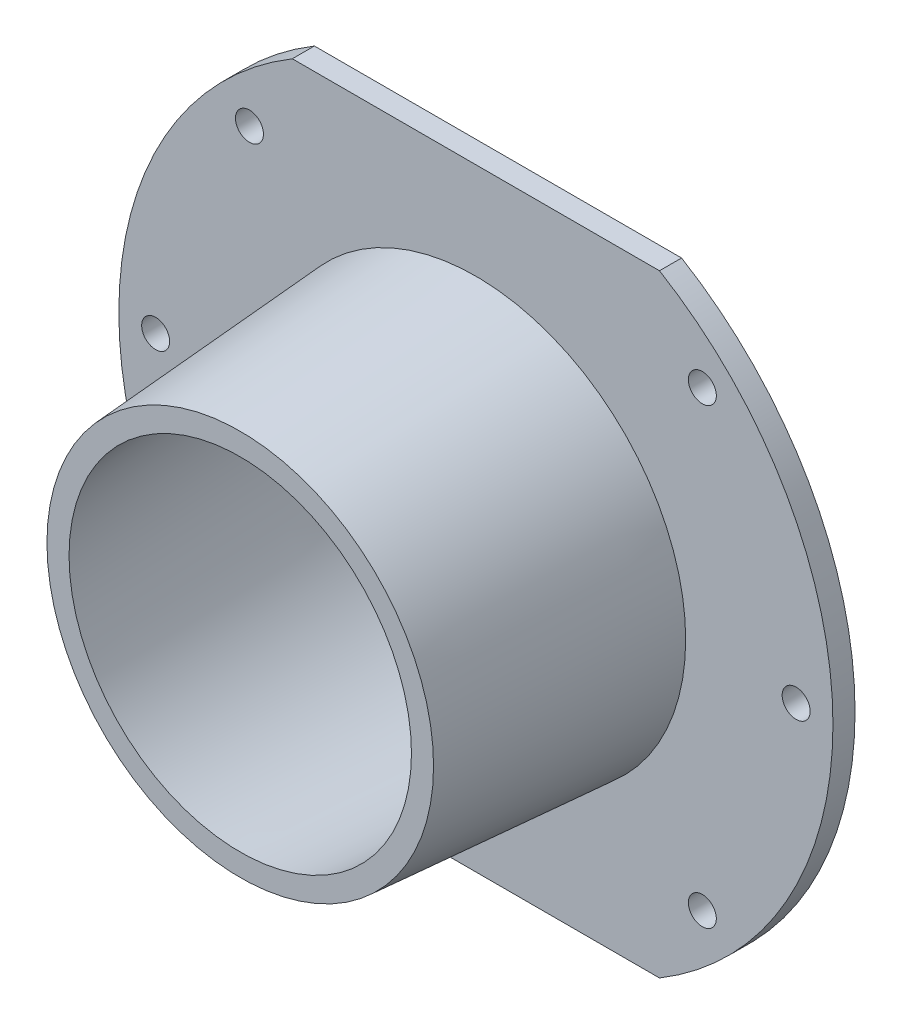
from build123d import *

# Parameters (mm, degrees)
SKETCH3_R          = 1.9
CUT_EXTRUDE1_DEPTH = 4
CIRPATTERN1_COUNT  = 8
SKETCH4_W          = 196.975315964
SKETCH4_H          = 183.175315964
SKETCH4_W_2        = 96.975315964
SKETCH4_H_2        = 83.175315964
CUT_EXTRUDE2_DEPTH = 4


with BuildPart() as part:
    # Sketch2 → Revolve1 (revolve)
    with BuildSketch(Plane(origin=(0, 0, 0), x_dir=(1, 0, 0), z_dir=(0, 1, 0))):
        Polygon((-28.697438418, 35), (-26.25, 0), (-23.25, 0), (-25.697438418, 35), align=None)
        Polygon((-28.487657982, 32), (-28.697438418, 35), (-48.487657982, 35), (-48.487657982, 32), align=None)
    revolve(axis=Axis((0, 0, 0), (0, 0, -1)))

    # Sketch3 → Cut-Extrude1 (cut, through all)
    with BuildSketch(Plane.XY.offset(-32)):
        with Locations((43.487657982, 0)):
            Circle(SKETCH3_R)
    cut_extrude1 = extrude(amount=-CUT_EXTRUDE1_DEPTH, mode=Mode.SUBTRACT)

    # CirPattern1: Cut-Extrude1 ×8 about axis
    cirpattern1_axis = Axis((0, 0, 0), (0, 0, 1))
    for i in range(1, CIRPATTERN1_COUNT):
        add(cut_extrude1.rotate(cirpattern1_axis, i * 360 / CIRPATTERN1_COUNT), mode=Mode.SUBTRACT)

    # Sketch4 → Cut-Extrude2 (cut, through all)
    with BuildSketch(Plane.XY.offset(-32)):
        Rectangle(SKETCH4_W, SKETCH4_H)
        Rectangle(SKETCH4_W_2, SKETCH4_H_2, mode=Mode.SUBTRACT)
    extrude(amount=-CUT_EXTRUDE2_DEPTH, mode=Mode.SUBTRACT)


solid = part.part
